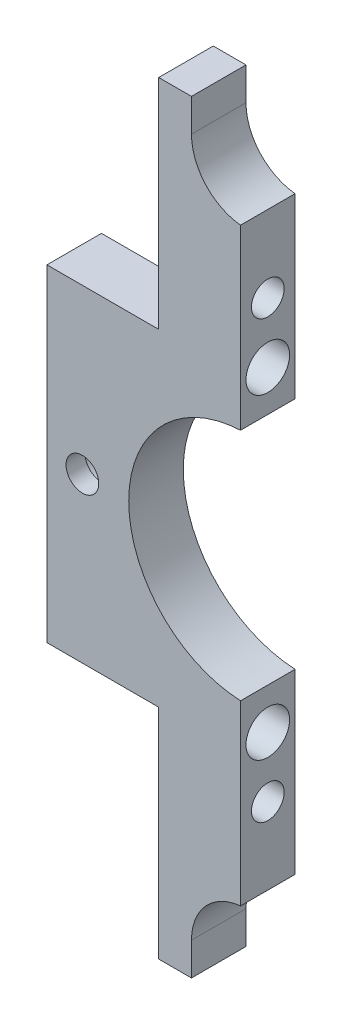
from build123d import *

# Parameters (mm, degrees)
SKETCH1_R           = 3
EXTRUDE3_DEPTH      = 10
SKETCH6_R           = 5
CUT_EXTRUDE4_DEPTH  = 6.5
SKETCH7_R           = 3
CUT_EXTRUDE5_DEPTH  = 15
SKETCH9_R           = 3
CUT_EXTRUDE10_DEPTH = 15
SKETCH12_R          = 4
CUT_EXTRUDE13_DEPTH = 10


with BuildPart() as part:
    # Sketch1 → Extrude3 (new body)
    with BuildSketch(Plane.XY):
        with BuildLine():
            Line((26.5, 134), (26.5, 140))
            Line((26.5, 140), (20.5, 140))
            Line((20.5, 140), (20.5, 100))
            Line((20.5, 100), (5.5, 100))
            Line((5.5, 100), (0, 100))
            Line((0, 100), (0, 40))
            Line((0, 40), (5.5, 40))
            Line((5.5, 40), (20.5, 40))
            Line((20.5, 40), (20.5, 0))
            Line((20.5, 0), (26.5, 0))
            Line((26.5, 0), (26.5, 6))
            ThreePointArc((26.5, 6), (29.083801513, 12.708203932), (35.5, 15.949874371))
            Line((35.5, 15.949874371), (35.5, 40))
            Line((35.5, 40), (35.5, 48.523268405))
            ThreePointArc((35.5, 48.523268405), (15, 70), (35.5, 91.476731595))
            Line((35.5, 91.476731595), (35.5, 100))
            Line((35.5, 100), (35.5, 124.050125629))
            ThreePointArc((35.5, 124.050125629), (29.083801513, 127.291796068), (26.5, 134))
        make_face()
        with Locations((6.5, 70)):
            Circle(SKETCH1_R, mode=Mode.SUBTRACT)
    extrude(amount=EXTRUDE3_DEPTH)

    # Sketch6 → Cut-Extrude4 (cut)
    with BuildSketch(Plane(origin=(0, 0, 0), x_dir=(-1, 0, 0), z_dir=(0, 0, -1))):
        with Locations((-6.5, 70)):
            Circle(SKETCH6_R)
    extrude(amount=-CUT_EXTRUDE4_DEPTH, mode=Mode.SUBTRACT)

    # Sketch7 → Cut-Extrude5 (cut)
    with BuildSketch(Plane.ZY.offset(-20.5)):
        with Locations((5, 30)):
            Circle(SKETCH7_R)
    extrude(amount=-CUT_EXTRUDE5_DEPTH, mode=Mode.SUBTRACT)

    # Sketch9 → Cut-Extrude10 (cut)
    with BuildSketch(Plane.ZY.offset(-20.5)):
        with Locations((5, 110)):
            Circle(SKETCH9_R)
    extrude(amount=-CUT_EXTRUDE10_DEPTH, mode=Mode.SUBTRACT)

    # Sketch12 → Cut-Extrude13 (cut)
    with BuildSketch(Plane(origin=(35.5, 0, 0), x_dir=(0, 0, -1), z_dir=(1, 0, 0))):
        with Locations((-5, 98.976731595)):
            Circle(SKETCH12_R)
        with Locations((-5, 41.023268405)):
            Circle(SKETCH12_R)
    extrude(amount=-CUT_EXTRUDE13_DEPTH, mode=Mode.SUBTRACT)


solid = part.part
